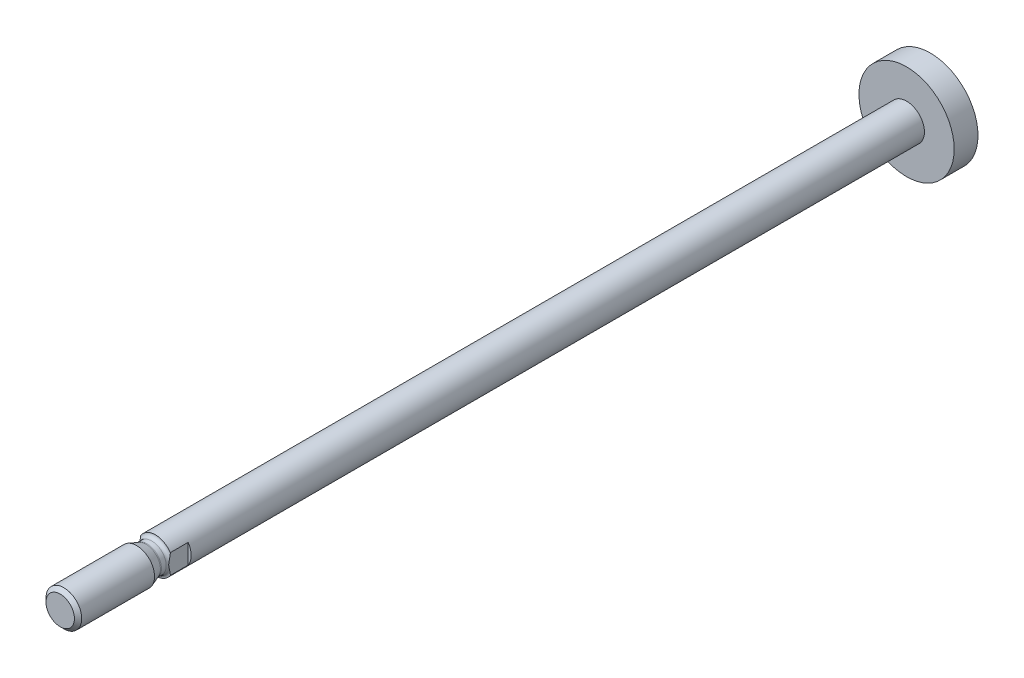
from build123d import *

# Parameters (mm, degrees)
CUT_EXTRUDE1_DEPTH = 4


with BuildPart() as part:
    # Sketch1 → Revolve1 (revolve)
    with BuildSketch(Plane(origin=(0, 0, 0), x_dir=(0, 0, -1), z_dir=(1, 0, 0))):
        Polygon((-5, 0), (-5, 3), (121.2, 3), (121.2, 8), (125.2, 8), (125.2, 0), align=None)
    revolve(axis=Axis((0, 0, -125.2), (0, 0, 1)))

    # Sketch2 → Revolve2 (revolve)
    with BuildSketch(Plane(origin=(0, 0, 0), x_dir=(0, 0, -1), z_dir=(1, 0, 0))):
        with BuildLine():
            Line((-21, 0), (-21, 2.3865))
            Line((-21, 2.3865), (-20.3865, 3))
            Line((-20.3865, 3), (-8.148486452, 3))
            Line((-8.148486452, 3), (-6.599415898, 2.436184428))
            ThreePointArc((-6.599415898, 2.436184428), (-6.498392718, 2.409115348), (-6.394203812, 2.4))
            Line((-6.394203812, 2.4), (-5.6, 2.4))
            ThreePointArc((-5.6, 2.4), (-5.175735931, 2.575735931), (-5, 3))
            Line((-5, 3), (-4, 3))
            Line((-4, 3), (-4, 0))
            Line((-4, 0), (-21, 0))
        make_face()
    revolve(axis=Axis((0, 0, 4), (0, 0, 1)))

    # Sketch3 → Cut-Extrude1 (cut)
    with BuildSketch(Plane.XY.offset(2)):
        Polygon((-5, 10), (-5, -5), (-2.5, -5), (-2.5, 5), (2.5, 5), (2.5, -5), (5, -5), (5, 10), align=None)
    extrude(amount=CUT_EXTRUDE1_DEPTH, mode=Mode.SUBTRACT)


solid = part.part
